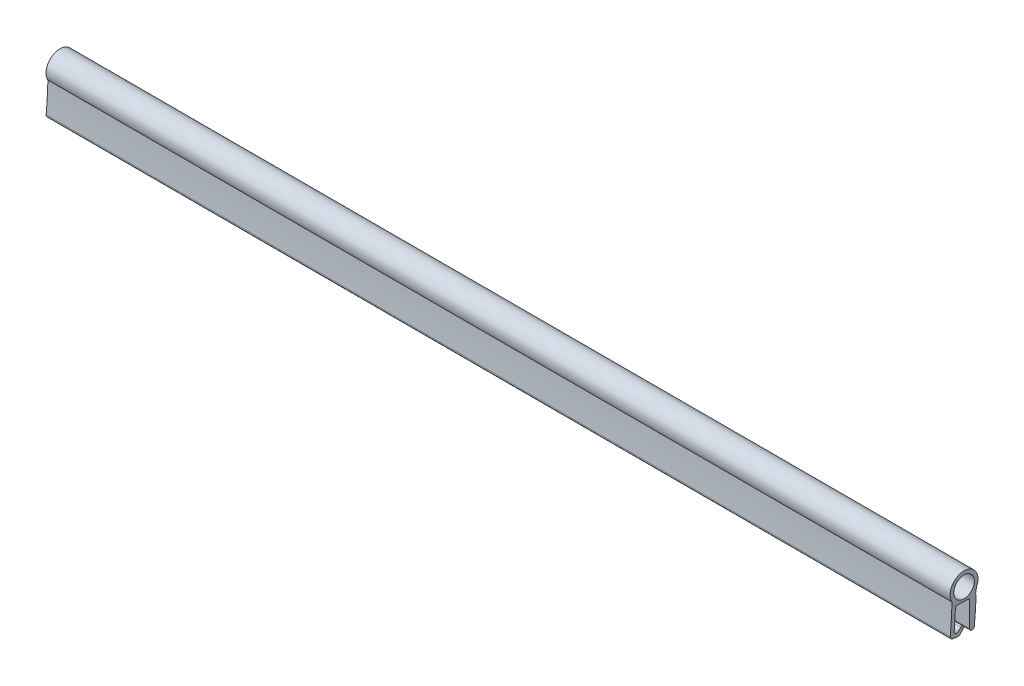
from build123d import *

# Parameters (mm, degrees)
ESQUISSE1_R        = 1.7
BOSS_EXTRU_3_DEPTH = 149


with BuildPart() as part:
    # Esquisse1 → Boss.-Extru.3 (new body)
    with BuildSketch(Plane(origin=(0, 0, 0), x_dir=(0, 0, -1), z_dir=(1, 0, 0))):
        with BuildLine():
            Line((-0.036458437, -2.338254983), (-0.016639213, -1.752889064))
            ThreePointArc((-0.016639213, -1.752889064), (-2.067142856, 1.648951077), (-4.023027898, -1.808156853))
            ThreePointArc((-4.023027898, -1.808156853), (-4.124891636, -4.209395962), (-4.307968961, -6.605811654))
            ThreePointArc((-4.307968961, -6.605811654), (-4.19616552, -6.970108995), (-3.860137757, -7.149825173))
            Line((-3.860137757, -7.149825173), (-2.997434267, -7.236530136))
            ThreePointArc((-2.997434267, -7.236530136), (-2.866648786, -7.22059768), (-2.755302232, -7.150165939))
            Line((-2.755302232, -7.150165939), (-2.1653982, -6.560261907))
            ThreePointArc((-2.1653982, -6.560261907), (-2.1653982, -6.135997838), (-2.589662269, -6.135997838))
            Line((-2.589662269, -6.135997838), (-3.011916745, -6.558252315))
            ThreePointArc((-3.011916745, -6.558252315), (-3.086147781, -6.605206809), (-3.173338102, -6.615828446))
            Line((-3.173338102, -6.615828446), (-3.40600808, -6.592444233))
            ThreePointArc((-3.40600808, -6.592444233), (-3.607097173, -6.485253599), (-3.674856447, -6.267686745))
            ThreePointArc((-3.674856447, -6.267686745), (-3.549218264, -4.620150364), (-3.461631357, -2.970153511))
            ThreePointArc((-3.461631357, -2.970153511), (-3.365882071, -2.762627683), (-3.151738054, -2.682770094))
            Line((-3.151738054, -2.682770094), (-1.386071808, -2.742551736))
            ThreePointArc((-1.386071808, -2.742551736), (-1.180532058, -2.833867893), (-1.096223342, -3.042379931))
            Line((-1.096223342, -3.042379931), (-1.096223342, -7.084255902))
            ThreePointArc((-1.096223342, -7.084255902), (-0.734671234, -7.463418189), (-0.338755541, -7.12029324))
            ThreePointArc((-0.338755541, -7.12029324), (-0.162274501, -4.931008235), (-0.049975817, -2.737494297))
            Line((-0.049975817, -2.737494297), (-0.242836784, -2.53111595))
            Line((-0.242836784, -2.53111595), (-0.036458437, -2.338254983))
        make_face()
        with Locations((-2.035417571, -0.65083011)):
            Circle(ESQUISSE1_R, mode=Mode.SUBTRACT)
    extrude(amount=BOSS_EXTRU_3_DEPTH)


solid = part.part
